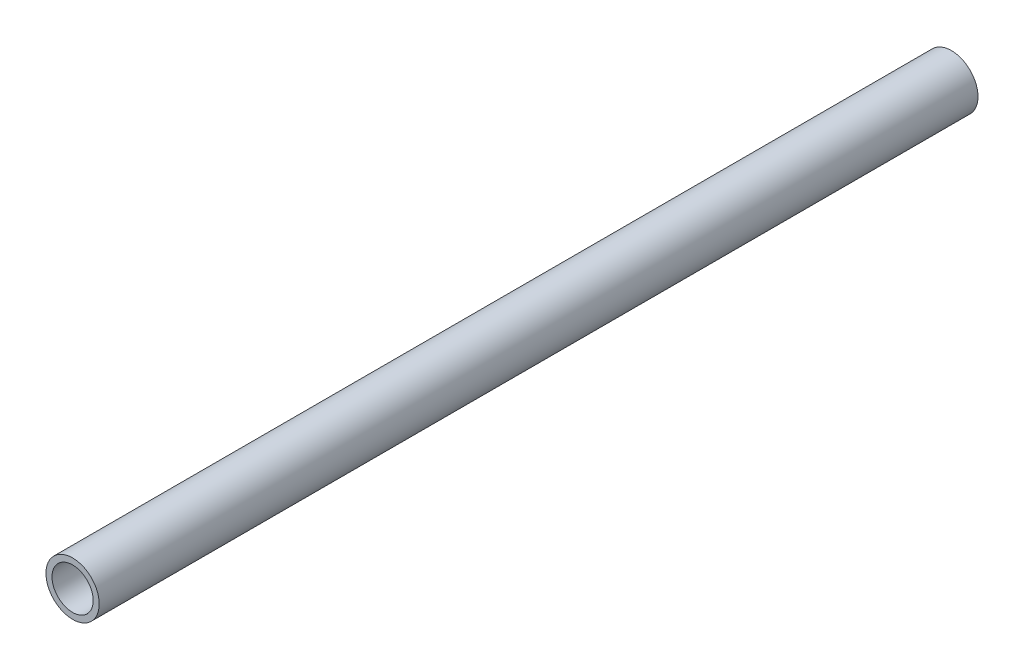
from build123d import *

# Parameters (mm, degrees)
SKETCH3_R                = 6.1595
SKETCH3_R_2              = 4.7625
BOSS_EXTRUDE1_DEPTH      = 101.6
BOSS_EXTRUDE1_DEPTH_BACK = 101.6


with BuildPart() as part:
    # Sketch3 → Boss-Extrude1 (new body, two sides)
    with BuildSketch(Plane.XY) as boss_extrude1_sk:
        Circle(SKETCH3_R)
        Circle(SKETCH3_R_2, mode=Mode.SUBTRACT)
    extrude(amount=BOSS_EXTRUDE1_DEPTH)
    extrude(boss_extrude1_sk.sketch, amount=-BOSS_EXTRUDE1_DEPTH_BACK)


solid = part.part
